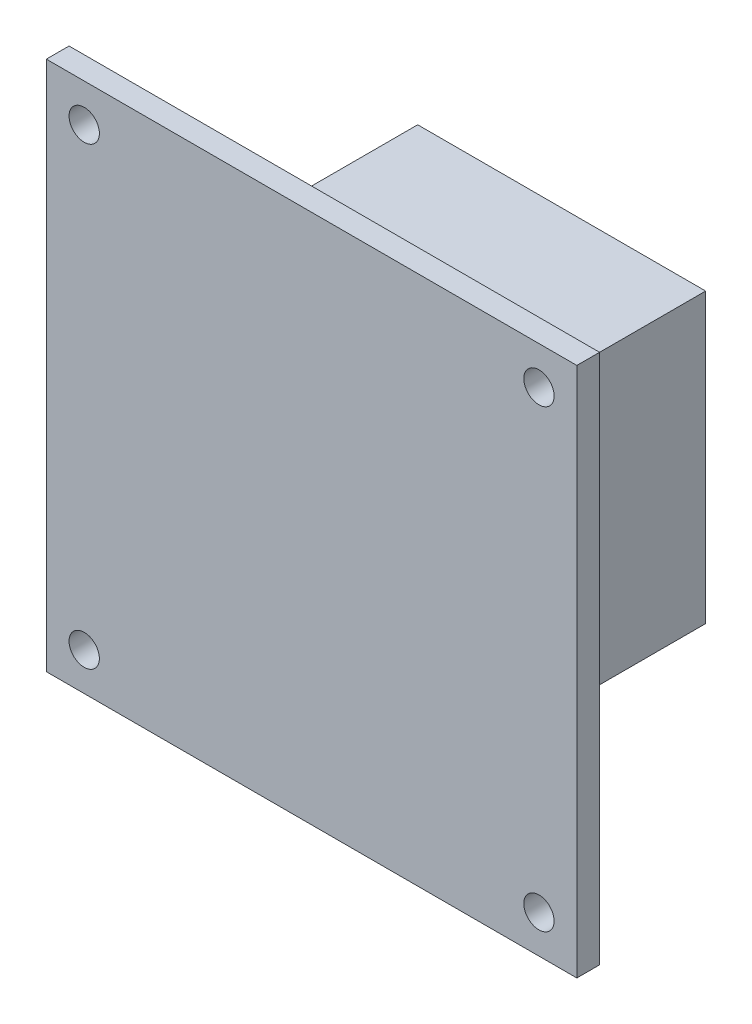
from build123d import *

# Parameters (mm, degrees)
SKETCH1_W           = 70
SKETCH1_H           = 70
BOSS_EXTRUDE1_DEPTH = 3
SKETCH3_R           = 2
CUT_EXTRUDE1_DEPTH  = 4
SKETCH5_W           = 38
SKETCH5_H           = 38
SKETCH5_W_2         = 35
SKETCH5_H_2         = 35
BOSS_EXTRUDE2_DEPTH = 30


with BuildPart() as part:
    # Sketch1 → Boss-Extrude1 (new body)
    with BuildSketch(Plane.XY):
        Rectangle(SKETCH1_W, SKETCH1_H)
    extrude(amount=BOSS_EXTRUDE1_DEPTH)

    # Sketch3 → Cut-Extrude1 (cut)
    with BuildSketch(Plane.XY.offset(3)):
        with Locations((-30, 30)):
            Circle(SKETCH3_R)
        with Locations((30, 30)):
            Circle(SKETCH3_R)
        with Locations((30, -30)):
            Circle(SKETCH3_R)
        with Locations((-30, -30)):
            Circle(SKETCH3_R)
    extrude(amount=-CUT_EXTRUDE1_DEPTH, mode=Mode.SUBTRACT)

    # Sketch5 → Boss-Extrude2 (add)
    with BuildSketch(Plane(origin=(0, 0, 0), x_dir=(-1, 0, 0), z_dir=(0, 0, -1))):
        Rectangle(SKETCH5_W, SKETCH5_H)
        Rectangle(SKETCH5_W_2, SKETCH5_H_2, mode=Mode.SUBTRACT)
    extrude(amount=BOSS_EXTRUDE2_DEPTH)


solid = part.part
